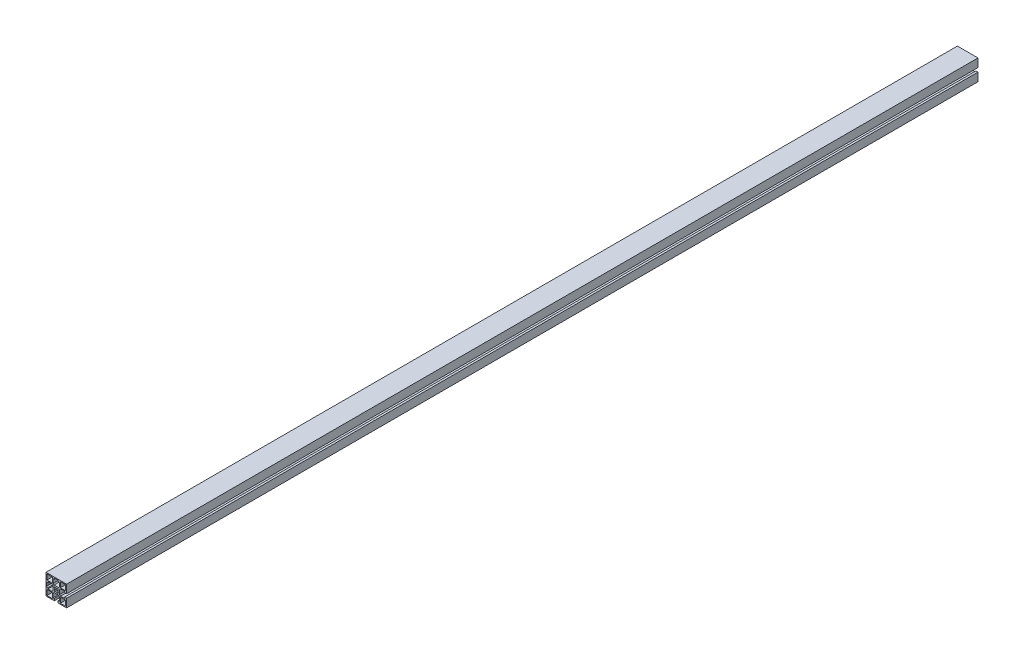
from build123d import *

# Parameters (mm, degrees)
SKETCH1_W           = 11.699975178
SKETCH1_H           = 11.699996949
SKETCH1_W_2         = 11.699990436
SKETCH1_H_2         = 11.699981689
SKETCH1_W_3         = 11.699990437
SKETCH1_H_3         = 11.699975177
SKETCH1_W_4         = 11.699981689
SKETCH1_H_4         = 11.699990436
BOSS_EXTRUDE1_DEPTH = 1990.725


with BuildPart() as part:
    # Sketch1 → Boss-Extrude1 (new body)
    with BuildSketch(Plane.XY):
        Polygon((22.500515052, 22.499297556), (-22.499484399, 22.499298105), (-22.499484948, -22.500701346), (-4.249491942, -22.500701568), (-4.249491942, -22.200733242), (-4.24949208, -18.000719999), (-6.799479919, -18.000719999), (-6.799480207, -9.200732353), (-4.799480391, -7.200732362), (4.800525817, -7.200732047), (6.8005258, -9.200731855), (6.800526088, -18.000720263), (4.250507877, -18.000720263), (4.250508015, -22.200733153), (4.250508015, -22.500701672), (22.500514502, -22.500701895), (22.500514725, -4.250714302), (22.200520351, -4.250714302), (18.000507108, -4.25071444), (18.000507108, -6.800702279), (9.200519462, -6.800702567), (7.200519471, -4.800702751), (7.200519156, 4.799303458), (9.200518964, 6.79930344), (18.000507424, 6.799303729), (18.000507424, 4.249285514), (22.200520261, 4.249285652), (22.500514829, 4.249285652), align=None)
        with BuildLine():
            Line((-4.249491247, 17.999291576), (-4.249490956, 22.199304807))
            Line((-4.249490956, 22.199304807), (-3.949472548, 22.199304807))
            Line((-3.949472548, 22.199304807), (-3.481695222, 21.73152644))
            ThreePointArc((-3.481695222, 21.73152644), (-2.670636178, 21.189593132), (-1.713926324, 20.999291428))
            Line((-1.713926324, 20.999291428), (1.714975167, 20.999291428))
            ThreePointArc((1.714975167, 20.999291428), (2.671722509, 21.189608628), (3.482801459, 21.731583767))
            Line((3.482801459, 21.731583767), (3.950490798, 22.199304487))
            Line((3.950490798, 22.199304487), (4.250509108, 22.199304487))
            Line((4.250509108, 22.199304487), (4.250508817, 17.999291575))
            Line((4.250508817, 17.999291575), (6.800527063, 17.999291575))
            Line((6.800527063, 17.999291575), (6.800526453, 9.199302988))
            Line((6.800526453, 9.199302988), (4.800526064, 7.199302969))
            Line((4.800526064, 7.199302969), (-4.799479817, 7.199303635))
            Line((-4.799479817, 7.199303635), (-6.799479854, 9.199304042))
            Line((-6.799479854, 9.199304042), (-6.799479244, 17.999291576))
            Line((-6.799479244, 17.999291576), (-4.249491247, 17.999291576))
        make_face(mode=Mode.SUBTRACT)
        with BuildLine():
            Line((-17.99949762, -4.250714253), (-22.199510799, -4.250714391))
            Line((-22.199510799, -4.250714391), (-22.199510799, -3.950696126))
            Line((-22.199510799, -3.950696126), (-21.731790056, -3.48300681))
            ThreePointArc((-21.731790056, -3.48300681), (-21.189814855, -2.671927844), (-20.999497617, -1.71518046))
            Line((-20.999497617, -1.71518046), (-20.999497617, 1.713721031))
            ThreePointArc((-20.999497617, 1.713721031), (-21.189799286, 2.670430863), (-21.731732544, 3.481489907))
            Line((-21.731732544, 3.481489907), (-22.199510888, 3.949267256))
            Line((-22.199510888, 3.949267256), (-22.199510888, 4.249285566))
            Line((-22.199510888, 4.249285566), (-17.999497356, 4.249285704))
            Line((-17.999497356, 4.249285704), (-17.999497356, 6.79927354))
            Line((-17.999497356, 6.79927354), (-9.199509947, 6.799273828))
            Line((-9.199509947, 6.799273828), (-7.199509956, 4.799274012))
            Line((-7.199509956, 4.799274012), (-7.199509641, -4.800732197))
            Line((-7.199509641, -4.800732197), (-9.199509449, -6.800732179))
            Line((-9.199509449, -6.800732179), (-17.99949762, -6.800732468))
            Line((-17.99949762, -6.800732468), (-17.99949762, -4.250714253))
        make_face(mode=Mode.SUBTRACT)
        with Locations((-14.649542346, -14.650709384)):
            Rectangle(SKETCH1_W, SKETCH1_H, mode=Mode.SUBTRACT)
        with Locations((14.65050626, -14.650767962)):
            Rectangle(SKETCH1_W_2, SKETCH1_H_2, mode=Mode.SUBTRACT)
        with BuildLine():
            Line((-3.181457266, -4.596908447), (-4.595670829, -3.182694885))
            Line((-4.595670829, -3.182694885), (-3.26221457, -1.849238626))
            ThreePointArc((-3.26221457, -1.849238626), (-3.749476751, -0.00071437), (-3.26221457, 1.847809887))
            Line((-3.26221457, 1.847809887), (-4.595670829, 3.181266146))
            Line((-4.595670829, 3.181266146), (-3.181457266, 4.595479708))
            Line((-3.181457266, 4.595479708), (-1.848001007, 3.262023449))
            ThreePointArc((-1.848001007, 3.262023449), (0.000523249, 3.74928563), (1.849047505, 3.262023449))
            Line((1.849047505, 3.262023449), (3.182503764, 4.595479708))
            Line((3.182503764, 4.595479708), (4.596717327, 3.181266146))
            Line((4.596717327, 3.181266146), (3.263261068, 1.847809887))
            ThreePointArc((3.263261068, 1.847809887), (3.750523249, -0.00071437), (3.263261068, -1.849238626))
            Line((3.263261068, -1.849238626), (4.596717327, -3.182694885))
            Line((4.596717327, -3.182694885), (3.182503764, -4.596908447))
            Line((3.182503764, -4.596908447), (1.849047505, -3.263452188))
            ThreePointArc((1.849047505, -3.263452188), (0.000523249, -3.75071437), (-1.848001007, -3.263452188))
            Line((-1.848001007, -3.263452188), (-3.181457266, -4.596908447))
        make_face(mode=Mode.SUBTRACT)
        with Locations((-14.64949028, 14.649335967)):
            Rectangle(SKETCH1_W_3, SKETCH1_H_3, mode=Mode.SUBTRACT)
        with Locations((14.650561583, 14.6492839)):
            Rectangle(SKETCH1_W_4, SKETCH1_H_4, mode=Mode.SUBTRACT)
    extrude(amount=BOSS_EXTRUDE1_DEPTH)


solid = part.part
